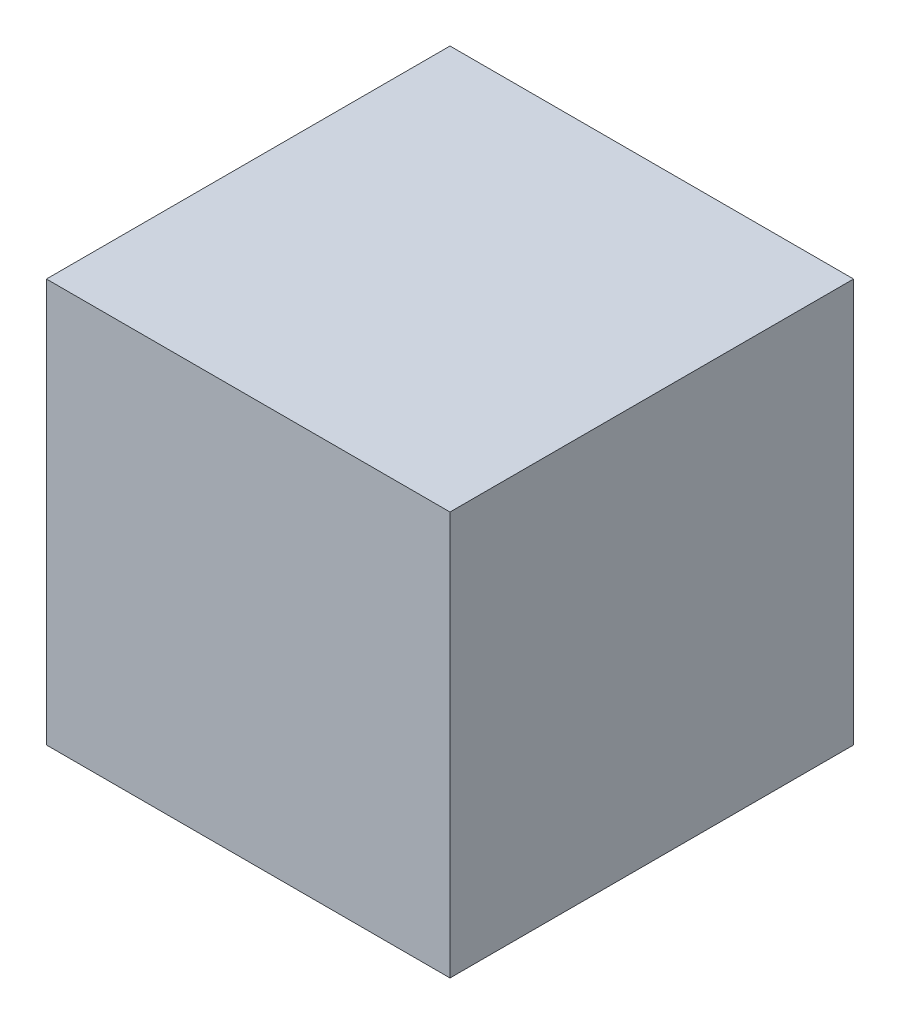
from build123d import *

# Parameters (mm, degrees)
SKETCH2_W           = 304.8
SKETCH2_H           = 304.8
BOSS_EXTRUDE1_DEPTH = 304.8


with BuildPart() as part:
    # Sketch2 → Boss-Extrude1 (new body)
    with BuildSketch(Plane(origin=(0, 0, 0), x_dir=(1, 0, 0), z_dir=(0, 1, 0))):
        with Locations((152.4, 152.4)):
            Rectangle(SKETCH2_W, SKETCH2_H)
    extrude(amount=BOSS_EXTRUDE1_DEPTH)


solid = part.part
